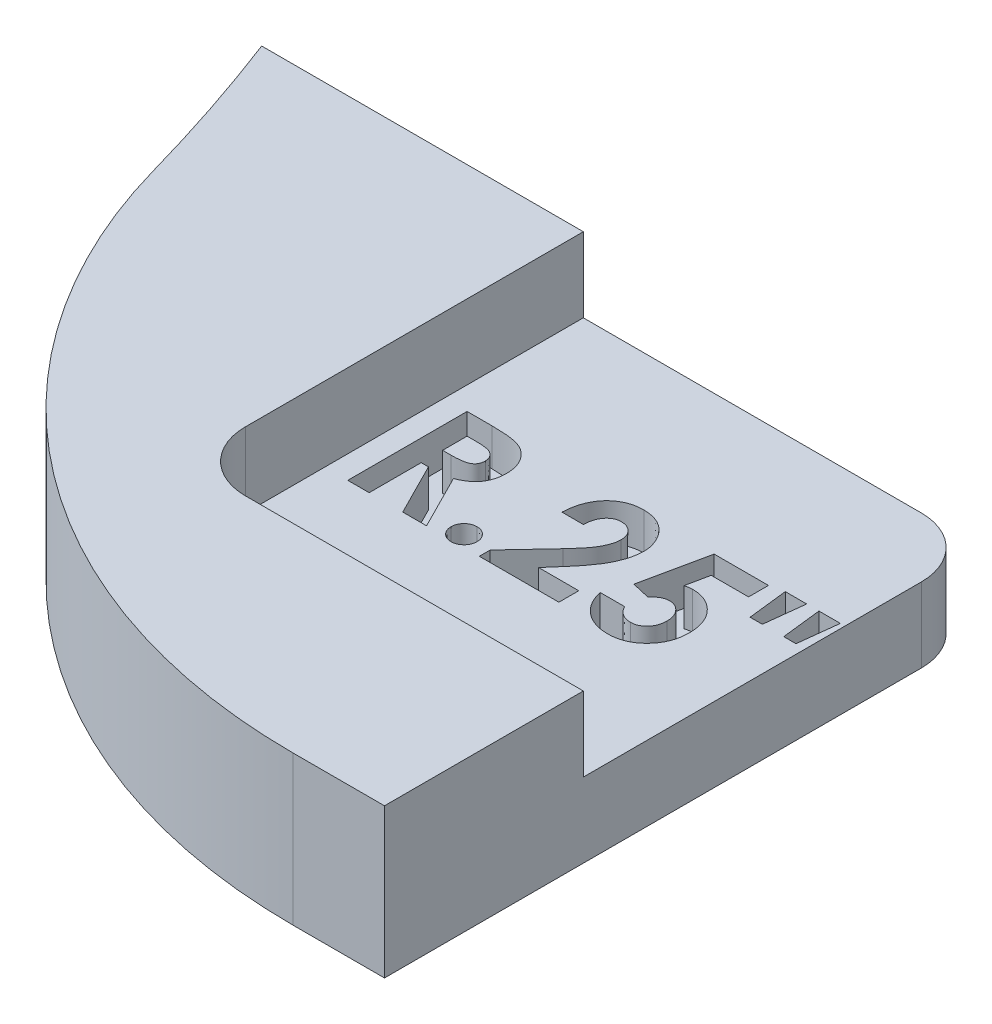
from build123d import *

# Parameters (mm, degrees)
BOSS_EXTRUDE1_DEPTH = 1.5875
FILLET1_R           = 12.7
SKETCH3_W           = 8.466666667
SKETCH3_H           = 8.466666667
CUT_EXTRUDE1_DEPTH  = 1.5875
CUT_EXTRUDE2_DEPTH  = 0.79375
FILLET2_R           = 1.27


with BuildPart() as part:
    # Sketch2 → Boss-Extrude1 (new, symmetric)
    with BuildSketch(Plane(origin=(0, 0, 0), x_dir=(1, 0, 0), z_dir=(0, 1, 0))):
        with BuildLine():
            Line((39.871809281, 1.5875), (52.571809281, 1.5875))
            Line((52.571809281, 1.5875), (52.571809281, 14.2875))
            Line((52.571809281, 14.2875), (37.257867294, 14.2875))
            ThreePointArc((37.257867294, 14.2875), (39.084130438, 8.044381855), (39.871809281, 1.5875))
        make_face()
    extrude(amount=BOSS_EXTRUDE1_DEPTH, both=True)

    # Fillet1
    fillet1_edges = [part.edges().sort_by_distance(p)[0] for p in [
        (39.871809281, 0, -1.5875),
    ]]
    fillet(fillet1_edges, radius=FILLET1_R)

    # Sketch3 → Cut-Extrude1 (cut)
    with BuildSketch(Plane(origin=(0, 1.5875, 0), x_dir=(1, 0, 0), z_dir=(0, 1, 0))):
        with Locations((48.338475948, 10.054166667)):
            Rectangle(SKETCH3_W, SKETCH3_H)
    extrude(amount=-CUT_EXTRUDE1_DEPTH, mode=Mode.SUBTRACT)

    # Sketch4 → Cut-Extrude2 (cut)
    with BuildSketch(Plane(origin=(0, 0, 0), x_dir=(1, 0, 0), z_dir=(0, 1, 0))):
        with BuildLine():
            Line((44.593604152, 11.324166667), (45.124806075, 11.324166667))
            add(Edge.make_bspline(
                [(45.124806075, 11.324166667), (45.159918361, 11.324042038), (45.227449176, 11.323802343), (45.324824924, 11.32002058), (45.414277939, 11.314757948), (45.495940666, 11.306727031), (45.569778167, 11.296079006), (45.635864445, 11.283526746), (45.694197569, 11.269220755), (45.745269497, 11.251394362), (45.791359386, 11.23128646), (45.834321571, 11.208182112), (45.875103861, 11.182338593), (45.91343367, 11.153075889), (45.949644094, 11.120920429), (45.983803445, 11.085839845), (46.01542902, 11.047536669), (46.044324993, 11.006252927), (46.070661346, 10.962823378), (46.093937159, 10.917188393), (46.112865088, 10.869316234), (46.129589943, 10.819898758), (46.141636314, 10.768229533), (46.150014389, 10.714811567), (46.156148488, 10.659456824), (46.156501169, 10.621851269), (46.156681075, 10.602668269)],
                knots=[0, 0, 0, 0, 1.749336639, 3.364467119, 4.854658419, 6.213483162, 7.451590619, 8.570285859, 9.5643256, 10.440900261, 11.26203566, 12.067320669, 12.869050712, 13.665104639, 14.467235401, 15.27997916, 16.102287765, 16.939272006, 17.78853747, 18.631303466, 19.488103222, 20.351255419, 21.228522269, 22.127379805, 23.044756219, 24, 24, 24, 24], degree=3))
            add(Edge.make_bspline(
                [(46.156681075, 10.602668269), (46.156213743, 10.582645624), (46.155297389, 10.543384867), (46.150361408, 10.485714017), (46.141339985, 10.430538582), (46.127675728, 10.378020108), (46.11197044, 10.327504941), (46.091086435, 10.27992512), (46.067516771, 10.234588662), (46.03952377, 10.192136871), (46.008802818, 10.151626807), (45.973074998, 10.114610561), (45.934654923, 10.079098649), (45.891382861, 10.047315418), (45.845166284, 10.0171118), (45.795086918, 9.989739279), (45.741471598, 9.964509772), (45.703777373, 9.950440056), (45.684501588, 9.943245192)],
                knots=[0, 0, 0, 0, 1.099860209, 2.156625411, 3.176576793, 4.16617041, 5.135385252, 6.078461593, 7.016046972, 7.938469504, 8.868247731, 9.803980173, 10.76021508, 11.73834243, 12.748633912, 13.790971185, 14.870363756, 16, 16, 16, 16], degree=3))
            Line((45.684501588, 9.943245192), (46.270655434, 8.784166667))
            Line((46.270655434, 8.784166667), (45.763876588, 8.784166667))
            Line((45.763876588, 8.784166667), (45.204181075, 9.891346154))
            Line((45.204181075, 9.891346154), (45.049501588, 9.891346154))
            Line((45.049501588, 9.891346154), (45.049501588, 8.784166667))
            Line((45.049501588, 8.784166667), (44.593604152, 8.784166667))
            Line((44.593604152, 8.784166667), (44.593604152, 11.324166667))
        make_face()
        with BuildLine():
            Line((45.049501588, 10.34724359), (45.22707771, 10.34724359))
            add(Edge.make_bspline(
                [(45.22707771, 10.34724359), (45.248787867, 10.347488104), (45.290358153, 10.347956297), (45.350141684, 10.350127967), (45.404439387, 10.355360621), (45.453484436, 10.361971884), (45.497523621, 10.369605541), (45.536164127, 10.380545035), (45.570001346, 10.39226698), (45.598634306, 10.406834317), (45.623097649, 10.423400538), (45.64422018, 10.442220178), (45.661691542, 10.464001514), (45.676071363, 10.488152625), (45.687257301, 10.51488712), (45.695422179, 10.543911516), (45.699985138, 10.575556438), (45.700510122, 10.597395742), (45.70078364, 10.608774038)],
                knots=[0, 0, 0, 0, 1.688639943, 3.233382647, 4.650958383, 5.928841754, 7.082724185, 8.122798841, 9.049171256, 9.863274652, 10.613301712, 11.341792392, 12.054588806, 12.776240173, 13.521029143, 14.301969904, 15.115324896, 16, 16, 16, 16], degree=3))
            add(Edge.make_bspline(
                [(45.70078364, 10.608774038), (45.70026653, 10.622235393), (45.699250765, 10.648677731), (45.68917122, 10.686745424), (45.673126761, 10.72197968), (45.651134202, 10.754221299), (45.623437433, 10.782486528), (45.591653205, 10.807402553), (45.555095539, 10.827104281), (45.521245891, 10.840099331), (45.490450623, 10.847874404), (45.462658866, 10.853668319), (45.430475843, 10.857774633), (45.393877259, 10.86213011), (45.352956405, 10.864954416), (45.307490237, 10.867015597), (45.257609334, 10.867858927), (45.222837607, 10.868128525), (45.20468989, 10.868269231)],
                knots=[0, 0, 0, 0, 1.020303359, 2.004196876, 2.966617323, 3.9489082, 4.950758222, 5.960522915, 7.003732012, 8.091992268, 8.70421221, 9.413913587, 10.24622431, 11.166358409, 12.212345909, 13.359657661, 14.621978493, 16, 16, 16, 16], degree=3))
            Line((45.20468989, 10.868269231), (45.049501588, 10.868269231))
            Line((45.049501588, 10.868269231), (45.049501588, 10.34724359))
        make_face(mode=Mode.SUBTRACT)
        with BuildLine():
            add(Edge.make_bspline(
                [(46.824245178, 9.305192308), (46.842649217, 9.304183258), (46.878883591, 9.302196615), (46.931237321, 9.287370501), (46.978486864, 9.260733275), (47.020734269, 9.22598963), (47.05645761, 9.184188387), (47.082277634, 9.13651918), (47.09835641, 9.084367176), (47.100131518, 9.048018804), (47.10104005, 9.029415064)],
                knots=[0, 0, 0, 0, 1.016957001, 2.002212695, 2.9757545, 3.99499976, 5.013036768, 5.994806404, 6.97370641, 8, 8, 8, 8], degree=3))
            add(Edge.make_bspline(
                [(47.10104005, 9.029415064), (47.10013747, 9.010808336), (47.09837399, 8.974454126), (47.08216637, 8.9222005), (47.056496194, 8.874139496), (47.020731403, 8.831890325), (46.978661825, 8.796491904), (46.931128686, 8.770100312), (46.878983324, 8.754433151), (46.842666771, 8.752555171), (46.824245178, 8.751602564)],
                knots=[0, 0, 0, 0, 1.023218912, 1.999186227, 2.986238111, 4.008388923, 5.030539734, 6.0011649, 6.986089706, 8, 8, 8, 8], degree=3))
            add(Edge.make_bspline(
                [(46.824245178, 8.751602564), (46.80581922, 8.752547424), (46.769494062, 8.754410133), (46.717267643, 8.770232371), (46.669383578, 8.796315704), (46.62730343, 8.831933263), (46.591378858, 8.873989888), (46.566438508, 8.922352141), (46.550079919, 8.974434426), (46.548340547, 9.010801666), (46.547450306, 9.029415064)],
                knots=[0, 0, 0, 0, 1.013427518, 1.99788335, 2.976245624, 3.997909735, 5.019573847, 6.001765691, 6.977268297, 8, 8, 8, 8], degree=3))
            add(Edge.make_bspline(
                [(46.547450306, 9.029415064), (46.548346421, 9.04802559), (46.550097267, 9.08438722), (46.566327562, 9.136365793), (46.591418829, 9.184338808), (46.627300434, 9.225946603), (46.66955944, 9.2609081), (46.717158399, 9.287240252), (46.769593745, 9.302219802), (46.805836753, 9.304191069), (46.824245178, 9.305192308)],
                knots=[0, 0, 0, 0, 1.025808215, 2.00424526, 2.981110158, 3.998665696, 5.017428914, 5.998734231, 6.983523959, 8, 8, 8, 8], degree=3))
        make_face()
        with BuildLine():
            Line((47.915142614, 10.4775), (47.459245178, 10.4775))
            add(Edge.make_bspline(
                [(47.459245178, 10.4775), (47.461214129, 10.511986229), (47.465061341, 10.57937025), (47.480364579, 10.677247699), (47.500870393, 10.769731124), (47.528238123, 10.85649701), (47.562627468, 10.937513829), (47.603153499, 11.01305777), (47.650851565, 11.082731093), (47.704706495, 11.146197795), (47.76380398, 11.20313436), (47.826917098, 11.253617894), (47.895011249, 11.295275637), (47.966842298, 11.329556102), (48.042398012, 11.3569446), (48.122393269, 11.375256028), (48.206135425, 11.387656706), (48.263463712, 11.388741816), (48.292682678, 11.389294872)],
                knots=[0, 0, 0, 0, 1.199038563, 2.342849363, 3.436047546, 4.486744587, 5.497670872, 6.488682221, 7.459191391, 8.424610317, 9.374430501, 10.305433194, 11.225809216, 12.140057399, 13.06607119, 14.010487599, 14.985989317, 16, 16, 16, 16], degree=3))
            add(Edge.make_bspline(
                [(48.292682678, 11.389294872), (48.328548545, 11.388175762), (48.398567121, 11.385990998), (48.500309666, 11.367354235), (48.595326079, 11.336181368), (48.683547292, 11.292624652), (48.764222262, 11.23729041), (48.837337612, 11.171313383), (48.900682215, 11.093309337), (48.954657696, 11.006523895), (48.99950487, 10.914630326), (49.030931901, 10.819608564), (49.051588551, 10.723980103), (49.05379171, 10.659588737), (49.054886204, 10.62760016)],
                knots=[0, 0, 0, 0, 1.075374347, 2.099382735, 3.09057751, 4.06680945, 5.040638231, 6.016817125, 7.011024321, 8.044445721, 9.0776792, 10.070479129, 11.0414456, 12, 12, 12, 12], degree=3))
            add(Edge.make_bspline(
                [(49.054886204, 10.62760016), (49.054460066, 10.608251208), (49.053602355, 10.569306547), (49.04763858, 10.510373716), (49.038691738, 10.450343738), (49.025202081, 10.389268082), (49.008379374, 10.327129628), (48.987970997, 10.263742418), (48.963503561, 10.199465833), (48.935385375, 10.133576451), (48.901840308, 10.065860356), (48.862781741, 9.995302456), (48.81717297, 9.921965343), (48.765564892, 9.84543493), (48.707706858, 9.765831919), (48.643316426, 9.683396098), (48.573135221, 9.59783699), (48.523325646, 9.540645528), (48.497734761, 9.511262019)],
                knots=[0, 0, 0, 0, 0.728284026, 1.46585585, 2.227944881, 3.01186502, 3.81876927, 4.650621989, 5.517437689, 6.406905708, 7.346299482, 8.360816762, 9.441613733, 10.596154504, 11.834900912, 13.145207542, 14.533280747, 16, 16, 16, 16], degree=3))
            Line((48.497734761, 9.511262019), (48.232642614, 9.2075))
            Line((48.232642614, 9.2075), (49.087450306, 9.2075))
            Line((49.087450306, 9.2075), (49.087450306, 8.784166667))
            Line((49.087450306, 8.784166667), (47.394116973, 8.784166667))
            Line((47.394116973, 8.784166667), (47.394116973, 9.015168269))
            Line((47.394116973, 9.015168269), (48.146144217, 9.815532853))
            add(Edge.make_bspline(
                [(48.146144217, 9.815532853), (48.167917338, 9.838879736), (48.210085417, 9.884095726), (48.270086247, 9.950500217), (48.324381699, 10.013516494), (48.371845911, 10.073815553), (48.414969745, 10.129441538), (48.451830311, 10.182071086), (48.482764856, 10.231228406), (48.516348691, 10.290503549), (48.548242296, 10.361199705), (48.577506608, 10.442644576), (48.595345231, 10.520487115), (48.597807525, 10.571210987), (48.598988768, 10.595544872)],
                knots=[0, 0, 0, 0, 1.246127091, 2.413378631, 3.493388633, 4.492180848, 5.408488754, 6.240484944, 6.999099869, 7.674939598, 8.898438119, 10.020720584, 11.050475521, 12, 12, 12, 12], degree=3))
            add(Edge.make_bspline(
                [(48.598988768, 10.595544872), (48.598105581, 10.619086028), (48.596394266, 10.664700793), (48.5775883, 10.729587554), (48.548453444, 10.788335891), (48.507398318, 10.83919034), (48.457667702, 10.880980812), (48.400199304, 10.912063392), (48.33546166, 10.929997897), (48.290079338, 10.932242657), (48.266733159, 10.933397436)],
                knots=[0, 0, 0, 0, 1.062038974, 2.057870785, 3.028805853, 4.01125022, 4.991535629, 5.949134679, 6.94496649, 8, 8, 8, 8], degree=3))
            add(Edge.make_bspline(
                [(48.266733159, 10.933397436), (48.254672225, 10.932970847), (48.23092834, 10.932131037), (48.196026685, 10.926540653), (48.162815252, 10.916688185), (48.130924381, 10.903487264), (48.100694419, 10.885989349), (48.072201614, 10.864420381), (48.045145761, 10.839328476), (48.019650947, 10.810792094), (47.996447338, 10.778945483), (47.975837978, 10.744079497), (47.958797468, 10.706215778), (47.943794383, 10.665854185), (47.932223287, 10.622561203), (47.923798093, 10.576595933), (47.917392981, 10.528033157), (47.915906382, 10.494650815), (47.915142614, 10.4775)],
                knots=[0, 0, 0, 0, 0.903469896, 1.778625579, 2.63899355, 3.493148037, 4.358286772, 5.247621495, 6.164656832, 7.118446693, 8.109501108, 9.111810964, 10.146451449, 11.215617525, 12.33435995, 13.498009769, 14.714554818, 16, 16, 16, 16], degree=3))
        make_face()
        with BuildLine():
            Line((49.852197902, 11.324166667), (51.008732358, 11.324166667))
            Line((51.008732358, 11.324166667), (51.008732358, 10.900833333))
            Line((51.008732358, 10.900833333), (50.213455915, 10.900833333))
            Line((50.213455915, 10.900833333), (50.114237165, 10.420512821))
            add(Edge.make_bspline(
                [(50.114237165, 10.420512821), (50.12775714, 10.424278304), (50.154421309, 10.431704612), (50.194590912, 10.439152259), (50.233520855, 10.443979587), (50.259066446, 10.444623488), (50.271460723, 10.444935897)],
                knots=[0, 0, 0, 0, 1.05461699, 2.079921384, 3.068411212, 4, 4, 4, 4], degree=3))
            add(Edge.make_bspline(
                [(50.271460723, 10.444935897), (50.298469151, 10.444317015), (50.351708712, 10.443097061), (50.429591435, 10.431515721), (50.504168742, 10.413275462), (50.57521242, 10.387261089), (50.642653068, 10.353402711), (50.706572438, 10.312443564), (50.76704898, 10.26431171), (50.823008375, 10.208977014), (50.874426205, 10.148218265), (50.919131076, 10.082501249), (50.957311825, 10.012763026), (50.987679473, 9.938570106), (51.01164821, 9.86038847), (51.028968554, 9.778168017), (51.039210939, 9.691811302), (51.040592062, 9.63289629), (51.04129646, 9.602848558)],
                knots=[0, 0, 0, 0, 1.01440847, 1.999622559, 2.951875003, 3.895578053, 4.836219714, 5.782137149, 6.743708247, 7.735272588, 8.734977101, 9.730283169, 10.717124674, 11.717316708, 12.737475749, 13.78628267, 14.87096371, 16, 16, 16, 16], degree=3))
            add(Edge.make_bspline(
                [(51.04129646, 9.602848558), (51.040435675, 9.572459714), (51.038737093, 9.512493641), (51.027655406, 9.424322304), (51.008096028, 9.339874067), (50.981229266, 9.258922865), (50.945834027, 9.182063671), (50.903266408, 9.10850028), (50.852806705, 9.03877873), (50.7949501, 8.973613752), (50.732052382, 8.91405171), (50.66508116, 8.861654868), (50.594506926, 8.81756335), (50.520327978, 8.781929949), (50.442969905, 8.753737437), (50.362409226, 8.733214633), (50.278254428, 8.721445946), (50.221124255, 8.719849775), (50.192085723, 8.719038462)],
                knots=[0, 0, 0, 0, 1.06808661, 2.107647099, 3.116961351, 4.110378221, 5.100014249, 6.085620622, 7.093190682, 8.119403071, 9.144090782, 10.133780668, 11.103064255, 12.062861538, 13.020824475, 13.992378307, 14.979551724, 16, 16, 16, 16], degree=3))
            add(Edge.make_bspline(
                [(50.192085723, 8.719038462), (50.166117428, 8.719702166), (50.114902516, 8.721011131), (50.039465199, 8.729056717), (49.966735248, 8.743281388), (49.897098781, 8.763868171), (49.829823103, 8.789205801), (49.765685943, 8.820895296), (49.704334855, 8.858333244), (49.645944053, 8.900836404), (49.591462304, 8.948714564), (49.541737137, 9.00112546), (49.496467509, 9.057408477), (49.456622119, 9.118257977), (49.42232587, 9.183584058), (49.391911257, 9.252616838), (49.367016592, 9.326077238), (49.354383266, 9.377004069), (49.347963127, 9.402884615)],
                knots=[0, 0, 0, 0, 1.054957082, 2.080596141, 3.077793124, 4.061112343, 5.027190972, 5.994718051, 6.962465889, 7.943658696, 8.924948258, 9.904494768, 10.875059, 11.855380583, 12.854004648, 13.869083016, 14.917087635, 16, 16, 16, 16], degree=3))
            Line((49.347963127, 9.402884615), (49.868988768, 9.402884615))
            add(Edge.make_bspline(
                [(49.868988768, 9.402884615), (49.878513129, 9.384950451), (49.897022638, 9.350097449), (49.932231817, 9.303824852), (49.971646257, 9.264365569), (50.014910419, 9.231334075), (50.062304628, 9.206587441), (50.111897659, 9.187820739), (50.164312528, 9.176976157), (50.200009369, 9.175620477), (50.218035242, 9.174935897)],
                knots=[0, 0, 0, 0, 1.104910296, 2.147267069, 3.153527244, 4.136738762, 5.099945312, 6.05603338, 7.018353, 8, 8, 8, 8], degree=3))
            add(Edge.make_bspline(
                [(50.218035242, 9.174935897), (50.230599034, 9.175408605), (50.255318506, 9.176338666), (50.29173874, 9.181258923), (50.326503453, 9.190577776), (50.359871113, 9.203482222), (50.391931354, 9.219575524), (50.42222458, 9.239892269), (50.451277841, 9.263277596), (50.478648826, 9.290112337), (50.50343905, 9.320026832), (50.525177365, 9.352171996), (50.544614416, 9.385833557), (50.559011736, 9.422344933), (50.570801925, 9.460615882), (50.579484696, 9.500935094), (50.584673632, 9.543349657), (50.585153988, 9.572304891), (50.585399024, 9.587075321)],
                knots=[0, 0, 0, 0, 0.978869489, 1.925942215, 2.855067702, 3.774946051, 4.70828698, 5.642468714, 6.60995405, 7.609372294, 8.622401667, 9.629904756, 10.629323, 11.642352373, 12.678539694, 13.745912462, 14.850161547, 16, 16, 16, 16], degree=3))
            add(Edge.make_bspline(
                [(50.585399024, 9.587075321), (50.585114632, 9.601502895), (50.584561055, 9.629586518), (50.579981755, 9.670823337), (50.571789476, 9.709949616), (50.560627425, 9.747265031), (50.546338668, 9.782542987), (50.528876851, 9.815993475), (50.508167376, 9.847447414), (50.484099059, 9.876264433), (50.458432853, 9.902696223), (50.4308591, 9.925813255), (50.401626226, 9.944998787), (50.371642606, 9.961748315), (50.339711401, 9.973938256), (50.306550617, 9.982333019), (50.272195126, 9.988492758), (50.248761991, 9.988854665), (50.236861364, 9.989038462)],
                knots=[0, 0, 0, 0, 1.166249705, 2.270133367, 3.348514167, 4.393962215, 5.415026464, 6.420877785, 7.440098956, 8.453121383, 9.451844239, 10.415694839, 11.355045125, 12.27538808, 13.187007209, 14.108269027, 15.039275622, 16, 16, 16, 16], degree=3))
            add(Edge.make_bspline(
                [(50.236861364, 9.989038462), (50.223934517, 9.98854796), (50.198026344, 9.987564888), (50.159533283, 9.9795659), (50.121504341, 9.966620537), (50.083728038, 9.948760356), (50.04657937, 9.925387015), (50.009077964, 9.897972766), (49.972479074, 9.864525703), (49.949208482, 9.839614255), (49.937169858, 9.826726763)],
                knots=[0, 0, 0, 0, 0.88288272, 1.769486374, 2.674910571, 3.623812639, 4.617874466, 5.670434592, 6.794841017, 8, 8, 8, 8], degree=3))
            Line((49.937169858, 9.826726763), (49.553524024, 9.914751603))
            Line((49.553524024, 9.914751603), (49.852197902, 11.324166667))
        make_face()
        Polygon((52.376424665, 10.542628205), (52.115911845, 10.542628205), (52.018219537, 11.389294872), (52.474116973, 11.389294872), align=None)
        Polygon((51.660014409, 10.542628205), (51.399501588, 10.542628205), (51.301809281, 11.389294872), (51.757706717, 11.389294872), align=None)
    extrude(amount=-CUT_EXTRUDE2_DEPTH, mode=Mode.SUBTRACT)

    # Fillet2
    fillet2_edges = [part.edges().sort_by_distance(p)[0] for p in [
        (52.571809281, -0.79375, -14.2875),
        (44.105142614, 0.79375, -5.820833333),
    ]]
    fillet(fillet2_edges, radius=FILLET2_R)


solid = part.part
